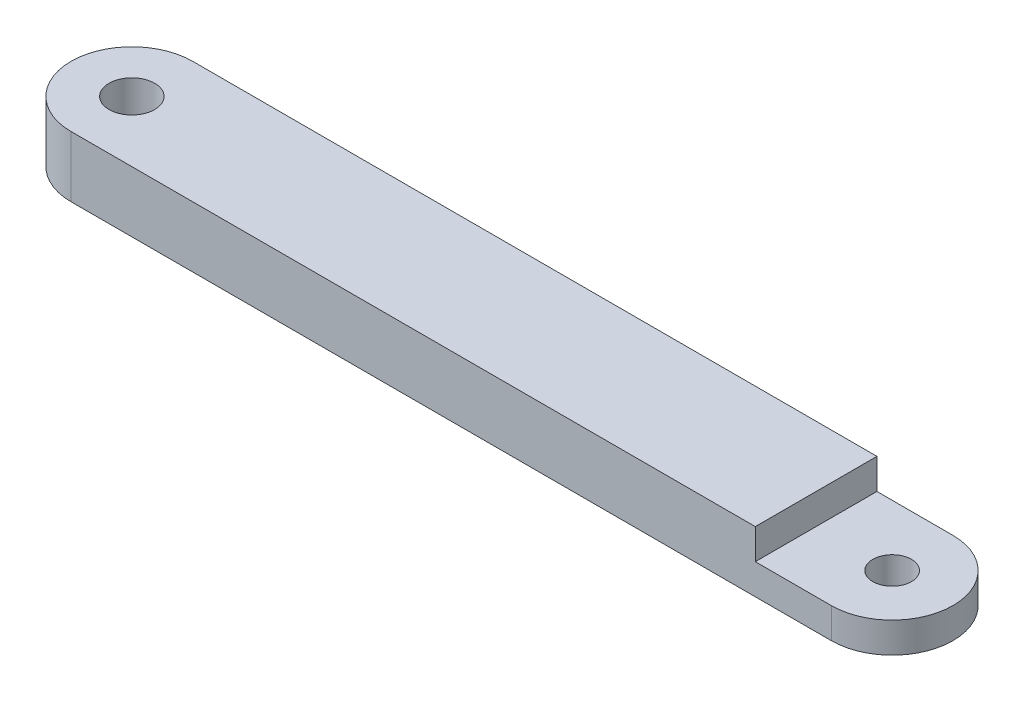
from build123d import *

# Parameters (mm, degrees)
BOSS_EXTRUDE1_DEPTH            = 6.35
F_3_16_0_1875_DIAMETER_HOLE1_D = 4.7625
F_21_0_159_DIAMETER_HOLE1_D    = 4.0386
SKETCH4_W                      = 15.875
SKETCH4_H                      = 12.7
CUT_EXTRUDE1_DEPTH             = 3.175


with BuildPart() as part:
    # Sketch1 → Boss-Extrude1 (new body)
    with BuildSketch(Plane(origin=(0, 0, 0), x_dir=(1, 0, 0), z_dir=(0, 1, 0))):
        with BuildLine():
            Line((-39.6875, 6.35), (39.6875, 6.35))
            ThreePointArc((39.6875, 6.35), (46.0375, 0), (39.6875, -6.35))
            Line((39.6875, -6.35), (-39.6875, -6.35))
            ThreePointArc((-39.6875, -6.35), (-46.0375, 0), (-39.6875, 6.35))
        make_face()
    extrude(amount=BOSS_EXTRUDE1_DEPTH)

    # 3/16 (0.1875) Diameter Hole1 (through all)
    with Locations(Plane(origin=(0, 6.35, 0), x_dir=(1, 0, 0), z_dir=(0, 1, 0))):
        with Locations((-39.6875, 0)):
            Hole(F_3_16_0_1875_DIAMETER_HOLE1_D / 2)

    # #21 (0.159) Diameter Hole1 (through all)
    with Locations(Plane(origin=(0, 6.35, 0), x_dir=(1, 0, 0), z_dir=(0, 1, 0))):
        with Locations((39.6875, 0)):
            Hole(F_21_0_159_DIAMETER_HOLE1_D / 2)

    # Sketch4 → Cut-Extrude1 (cut)
    with BuildSketch(Plane(origin=(0, 6.35, 0), x_dir=(1, 0, 0), z_dir=(0, 1, 0))):
        with Locations((39.6875, 0)):
            Rectangle(SKETCH4_W, SKETCH4_H)
    extrude(amount=-CUT_EXTRUDE1_DEPTH, mode=Mode.SUBTRACT)


solid = part.part
